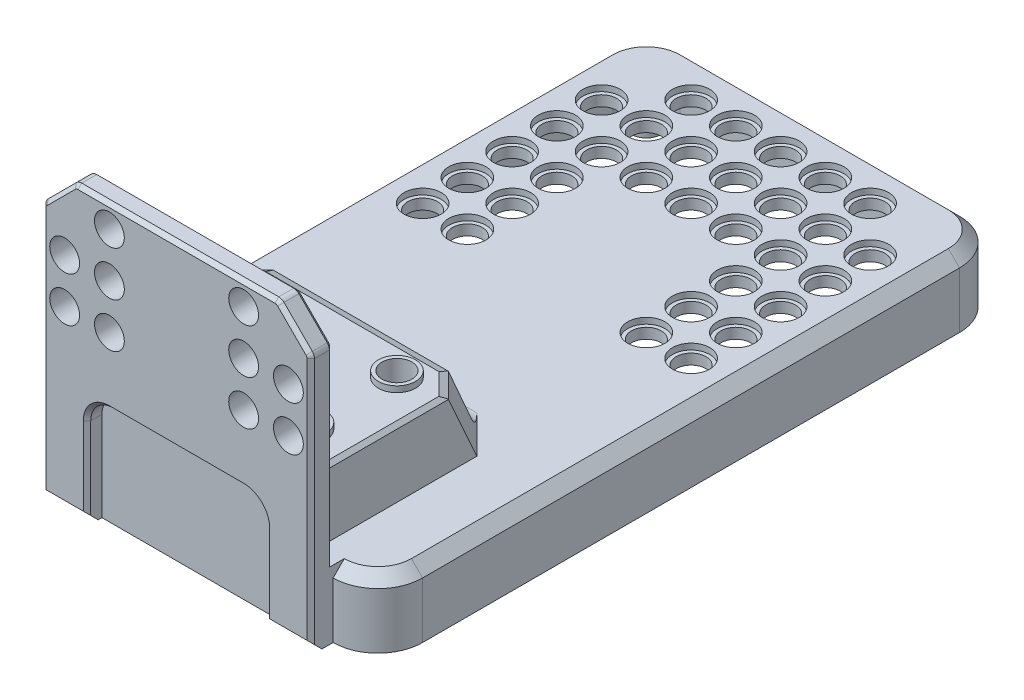
from build123d import *
from OCP.BRepFilletAPI import BRepFilletAPI_MakeChamfer

# Parameters (mm, degrees)
BOSS_EXTRUDE1_DEPTH  = 1.1
BOSS_EXTRUDE2_DEPTH  = 6.8
BOSS_EXTRUDE3_DEPTH  = 3
FILLET1_R            = 1
FILLET3_R            = 3
CUT_EXTRUDE1_DEPTH   = 2
CHAMFER2_SIZE        = 1.5
CHAMFER3_SIZE        = 0.5
CHAMFER3_SIZE2       = 0.766184228
CHAMFER3_SIZE2_2     = 0.943071923
SKETCH10_R           = 2
CUT_EXTRUDE2_DEPTH   = 93.731925463
SKETCH11_R           = 2
CUT_EXTRUDE3_DEPTH   = 60.16924877
SKETCH12_R           = 2.5
CUT_EXTRUDE4_DEPTH   = 0.8
LPATTERN1_COUNT      = 7
LPATTERN1_PITCH      = 6
LPATTERN1_COUNT_DIR2 = 6
LPATTERN1_PITCH_DIR2 = 6
SKETCH13_R           = 2
CUT_EXTRUDE5_DEPTH   = 56.154328933
SKETCH14_R           = 2.5
SKETCH14_R_2         = 2
BOSS_EXTRUDE5_DEPTH  = 0.8
LPATTERN5_COUNT      = 2
LPATTERN5_PITCH      = 19
LPATTERN5_COUNT_DIR2 = 2
LPATTERN5_PITCH_DIR2 = 12
SKETCH15_R           = 2
SKETCH15_R_2         = 0.8
BOSS_EXTRUDE4_DEPTH  = 3.8
LPATTERN4_COUNT      = 2
LPATTERN4_PITCH      = 72
LPATTERN4_COUNT_DIR2 = 2
LPATTERN4_PITCH_DIR2 = 36


with BuildPart() as part:
    # Sketch1 → Boss-Extrude1 (new, symmetric)
    with BuildSketch(Plane(origin=(0, 0, 0), x_dir=(1, 0, 0), z_dir=(0, 1, 0))):
        with BuildLine():
            Line((-24, 36), (-24, -36))
            ThreePointArc((-24, -36), (-22.242640687, -40.242640687), (-18, -42))
            Line((-18, -42), (18, -42))
            ThreePointArc((18, -42), (22.242640687, -40.242640687), (24, -36))
            Line((24, -36), (24, 36))
            ThreePointArc((24, 36), (22.242640687, 40.242640687), (18, 42))
            Line((18, 42), (-18, 42))
            ThreePointArc((-18, 42), (-22.242640687, 40.242640687), (-24, 36))
        make_face()
    extrude(amount=BOSS_EXTRUDE1_DEPTH, both=True)

    # Sketch2 → Boss-Extrude2 (add)
    with BuildSketch(Plane.XZ.offset(1.1)):
        with BuildLine():
            Line((24, 36), (24, -36))
            ThreePointArc((24, -36), (22.242640687, -40.242640687), (18, -42))
            Line((18, -42), (-18, -42))
            ThreePointArc((-18, -42), (-22.242640687, -40.242640687), (-24, -36))
            Line((-24, -36), (-24, 36))
            ThreePointArc((-24, 36), (-22.242640687, 40.242640687), (-18, 42))
            Line((-18, 42), (18, 42))
            ThreePointArc((18, 42), (22.242640687, 40.242640687), (24, 36))
        make_face()
        with BuildLine():
            Line((18, -40.5), (-18, -40.5))
            ThreePointArc((-18, -40.5), (-21.181980515, -39.181980515), (-22.5, -36))
            Line((-22.5, -36), (-22.5, 36))
            ThreePointArc((-22.5, 36), (-21.181980515, 39.181980515), (-18, 40.5))
            Line((-18, 40.5), (18, 40.5))
            ThreePointArc((18, 40.5), (21.181980515, 39.181980515), (22.5, 36))
            Line((22.5, 36), (22.5, -36))
            ThreePointArc((22.5, -36), (21.181980515, -39.181980515), (18, -40.5))
        make_face(mode=Mode.SUBTRACT)
    extrude(amount=BOSS_EXTRUDE2_DEPTH)

    # Sketch4 → Loft1 section 0
    with BuildSketch(Plane.XZ.offset(1.1)):
        Polygon((15, 18.75), (12, 15.75), (-12, 15.75), (-15, 18.75), (-15, 42), (15, 42), align=None)
    # Sketch5 → Loft1 section 1
    with BuildSketch(Plane(origin=(0, 10.1, 0), x_dir=(-1, 0, 0), z_dir=(0, -1, 0))):
        Polygon((-15, -42), (15, -42), (15, -23.75), (11.75, -20.5), (-11.75, -20.5), (-15, -23.75), align=None)
    loft()

    # Sketch6 → Boss-Extrude3 (add)
    with BuildSketch(Plane.XY.offset(42)):
        Polygon((18, -7.9), (-18, -7.9), (-18, 26.725), (-13.625, 31.1), (13.625, 31.1), (18, 26.725), align=None)
    extrude(amount=BOSS_EXTRUDE3_DEPTH)

    # Fillet1
    fillet1_edges = [part.edges().sort_by_distance(p)[0] for p in [
        (18, 26.725, 43.5),
        (13.625, 31.1, 43.5),
        (-13.625, 31.1, 43.5),
        (-18, 26.725, 43.5),
    ]]
    fillet(fillet1_edges, radius=FILLET1_R)

    # Sketch7 → Cut-Loft1 section 0
    with BuildSketch(Plane(origin=(0, 7.9, 0), x_dir=(-1, 0, 0), z_dir=(0, -1, 0))):
        Polygon((13.5, -42), (-13.5, -42), (-13.5, -24.371320344), (-11.128679656, -22), (11.128679656, -22), (13.5, -24.371320344), align=None)
    # Sketch8 → Cut-Loft1 section 1
    with BuildSketch(Plane.XZ.offset(1.1)):
        Polygon((13.5, 42), (-13.5, 42), (-13.5, 19), (-11.128679656, 16.628679656), (11.128679656, 16.628679656), (13.5, 19), align=None)
    loft(mode=Mode.SUBTRACT)

    # Fillet3
    fillet3_edges = [part.edges().sort_by_distance(p)[0] for p in [
        (0, -1.1, 16.628679656),
        (0, 1.1, 16.683035714),
    ]]
    fillet(fillet3_edges, radius=FILLET3_R)

    # Sketch9 → Cut-Extrude1 (cut)
    with BuildSketch(Plane.XY.offset(45)):
        with BuildLine():
            Line((12, -7.9), (-12, -7.9))
            Line((-12, -7.9), (-12, 4.1))
            ThreePointArc((-12, 4.1), (-11.121320344, 6.221320344), (-9, 7.1))
            Line((-9, 7.1), (9, 7.1))
            ThreePointArc((9, 7.1), (11.121320344, 6.221320344), (12, 4.1))
            Line((12, 4.1), (12, -7.9))
        make_face()
    extrude(amount=-CUT_EXTRUDE1_DEPTH, mode=Mode.SUBTRACT)

    # Chamfer2
    chamfer2_edges = [part.edges().sort_by_distance(p)[0] for p in [
        (-15.75, -1.1, 40.5),
        (-21.181980515, -1.1, 39.181980515),
        (-22.5, -1.1, 0),
        (-21.181980515, -1.1, -39.181980515),
        (0, -1.1, -40.5),
        (15.75, -1.1, 40.5),
        (21.181980515, -1.1, -39.181980515),
        (21.181980515, -1.1, 39.181980515),
        (22.5, -1.1, 0),
        (22.242640687, 1.1, 40.242640687),
        (24, 1.1, 0),
        (22.242640687, 1.1, -40.242640687),
        (0, 1.1, -42),
        (-22.242640687, 1.1, -40.242640687),
        (-22.242640687, 1.1, 40.242640687),
        (-24, 1.1, 0),
        (15, -7.9, 45),
        (-15, -7.9, 45),
    ]]
    chamfer(chamfer2_edges, length=CHAMFER2_SIZE)

    # Chamfer3: one chamfer whose edges measure the first distance from different faces: ONE call of the kernel's chamfer builder (chamfer() names one face for all edges)
    chamfer3_edges_1 = [part.edges().sort_by_distance(p)[0] for p in [
        (18, 13.705393219, 42),
        (-18, 13.705393219, 42),
        (-18, 9.955393219, 45),
        (-15.8125, 28.9125, 42),
        (0, 31.1, 42),
        (15.8125, 28.9125, 42),
        (13.59346987, 31.023879533, 42),
        (17.923879533, 26.69346987, 42),
        (-13.59346987, 31.023879533, 42),
        (-17.923879533, 26.69346987, 42),
        (-15.8125, 28.9125, 45),
        (15.8125, 28.9125, 45),
        (0, 31.1, 45),
        (13.59346987, 31.023879533, 45),
        (17.923879533, 26.69346987, 45),
        (-13.59346987, 31.023879533, 45),
        (-17.923879533, 26.69346987, 45),
        (11.121320344, 6.221320344, 45),
        (0, 7.1, 45),
        (-11.121320344, 6.221320344, 45),
        (-12, -1.15, 45),
        (12, -1.15, 45),
        (18, 9.955393219, 45),
        (15, 5.6, 42),
        (0, 10.1, 42),
        (-15, 5.6, 42),
        (-15, 10.1, 32.875),
        (15, 10.1, 32.875),
    ]]
    chamfer3_edges_2 = [part.edges().sort_by_distance(p)[0] for p in [
        (13.375, 10.1, 22.125),
    ]]
    chamfer3_side_2 = [part.faces().sort_by_distance(p)[0] for p in [
        (13.379088774, 5.548236922, 20.097051686),
    ]]
    chamfer3_edges_3 = [part.edges().sort_by_distance(p)[0] for p in [
        (0, 10.1, 20.5),
    ]]
    chamfer3_side_3 = [part.faces().sort_by_distance(p)[0] for p in [
        (0, 6.50624717, 18.975863755),
    ]]
    chamfer3_edges_4 = [part.edges().sort_by_distance(p)[0] for p in [
        (-13.375, 10.1, 22.125),
    ]]
    chamfer3_side_4 = [part.faces().sort_by_distance(p)[0] for p in [
        (-13.379144185, 5.548246835, 20.097111522),
    ]]
    chamfer3 = BRepFilletAPI_MakeChamfer(part.part.solid().wrapped)
    for e in chamfer3_edges_1:
        chamfer3.Add(CHAMFER3_SIZE, e.wrapped)
    for e in chamfer3_edges_2:
        chamfer3.Add(CHAMFER3_SIZE, CHAMFER3_SIZE2, e.wrapped, chamfer3_side_2[0].wrapped)  # the first distance lies on this face
    for e in chamfer3_edges_3:
        chamfer3.Add(CHAMFER3_SIZE, CHAMFER3_SIZE2_2, e.wrapped, chamfer3_side_3[0].wrapped)  # the first distance lies on this face
    for e in chamfer3_edges_4:
        chamfer3.Add(CHAMFER3_SIZE, CHAMFER3_SIZE2, e.wrapped, chamfer3_side_4[0].wrapped)  # the first distance lies on this face
    add(Compound.cast(chamfer3.Shape()), mode=Mode.REPLACE)

    # Sketch10 → Cut-Extrude2 (cut, through all)
    with BuildSketch(Plane(origin=(0, 0, 42), x_dir=(-1, 0, 0), z_dir=(0, 0, -1))):
        with Locations((-15, 16.1)):
            Circle(SKETCH10_R)
        with Locations((-9, 16.1)):
            Circle(SKETCH10_R)
        with Locations((9, 16.1)):
            Circle(SKETCH10_R)
        with Locations((15, 16.1)):
            Circle(SKETCH10_R)
        with Locations((-9, 22.1)):
            Circle(SKETCH10_R)
        with Locations((9, 22.1)):
            Circle(SKETCH10_R)
        with Locations((15, 22.1)):
            Circle(SKETCH10_R)
        with Locations((-9, 28.1)):
            Circle(SKETCH10_R)
        with Locations((9, 28.1)):
            Circle(SKETCH10_R)
        with Locations((-15, 22.1)):
            Circle(SKETCH10_R)
    extrude(amount=-CUT_EXTRUDE2_DEPTH, mode=Mode.SUBTRACT)

    # Sketch11 → Cut-Extrude3 (cut, through all)
    with BuildSketch(Plane(origin=(0, 1.1, 0), x_dir=(1, 0, 0), z_dir=(0, 1, 0))):
        with Locations(Location((18, 6, 0), (0, 0, 270))):
            Circle(SKETCH11_R)
    cut_extrude3 = extrude(amount=-CUT_EXTRUDE3_DEPTH, mode=Mode.SUBTRACT)

    # Sketch12 → Cut-Extrude4 (cut)
    with BuildSketch(Plane(origin=(0, 1.1, 0), x_dir=(1, 0, 0), z_dir=(0, 1, 0))):
        with Locations(Location((18, 6, 0), (0, 0, 270))):
            Circle(SKETCH12_R)
    cut_extrude4 = extrude(amount=-CUT_EXTRUDE4_DEPTH, mode=Mode.SUBTRACT)

    # LPattern1: Cut-Extrude3, Cut-Extrude4 7 × 6, 11 skipped
    with Locations(*[(-i * LPATTERN1_PITCH, 0, -j * LPATTERN1_PITCH_DIR2) for i in range(LPATTERN1_COUNT) for j in range(LPATTERN1_COUNT_DIR2) if (i, j) not in ((0, 0), (0, 5), (2, 0), (2, 1), (2, 2), (3, 0), (3, 1), (3, 2), (4, 0), (4, 1), (4, 2), (6, 5))]):
        add(cut_extrude3, mode=Mode.SUBTRACT)
        add(cut_extrude4, mode=Mode.SUBTRACT)

    # Sketch13 → Cut-Extrude5 (cut, through all)
    with BuildSketch(Plane(origin=(0, 10.1, 0), x_dir=(1, 0, 0), z_dir=(0, 1, 0))):
        with Locations(Location((9.5, -24.943071923, 0), (0, 0, 270))):
            Circle(SKETCH13_R)
    cut_extrude5 = extrude(amount=-CUT_EXTRUDE5_DEPTH, mode=Mode.SUBTRACT)

    # Sketch14 → Boss-Extrude5 (add)
    with BuildSketch(Plane(origin=(0, 10.1, 0), x_dir=(1, 0, 0), z_dir=(0, 1, 0))):
        with Locations(Location((9.5, -24.943071923, 0), (0, 0, 270))):
            Circle(SKETCH14_R)
        with Locations(Location((9.5, -24.943071923, 0), (0, 0, 270))):
            Circle(SKETCH14_R_2, mode=Mode.SUBTRACT)
    boss_extrude5 = extrude(amount=BOSS_EXTRUDE5_DEPTH)

    # LPattern5: Cut-Extrude5, Boss-Extrude5 2 × 2
    with Locations(*[(-i * LPATTERN5_PITCH, 0, j * LPATTERN5_PITCH_DIR2) for i in range(LPATTERN5_COUNT) for j in range(LPATTERN5_COUNT_DIR2) if (i, j) != (0, 0)]):
        add(cut_extrude5, mode=Mode.SUBTRACT)
        add(boss_extrude5)

    # Sketch15 → Boss-Extrude4 (add)
    with BuildSketch(Plane.XZ.offset(1.1)):
        with Locations(Location((18, -36, 0), (0, 0, 90))):
            Circle(SKETCH15_R)
        with Locations(Location((18, -36, 0), (0, 0, 90))):
            Circle(SKETCH15_R_2, mode=Mode.SUBTRACT)
    boss_extrude4 = extrude(amount=BOSS_EXTRUDE4_DEPTH)

    # LPattern4: Boss-Extrude4 2 × 2
    with Locations(*[(-j * LPATTERN4_PITCH_DIR2, 0, i * LPATTERN4_PITCH) for i in range(LPATTERN4_COUNT) for j in range(LPATTERN4_COUNT_DIR2) if (i, j) != (0, 0)]):
        add(boss_extrude4)


solid = part.part
